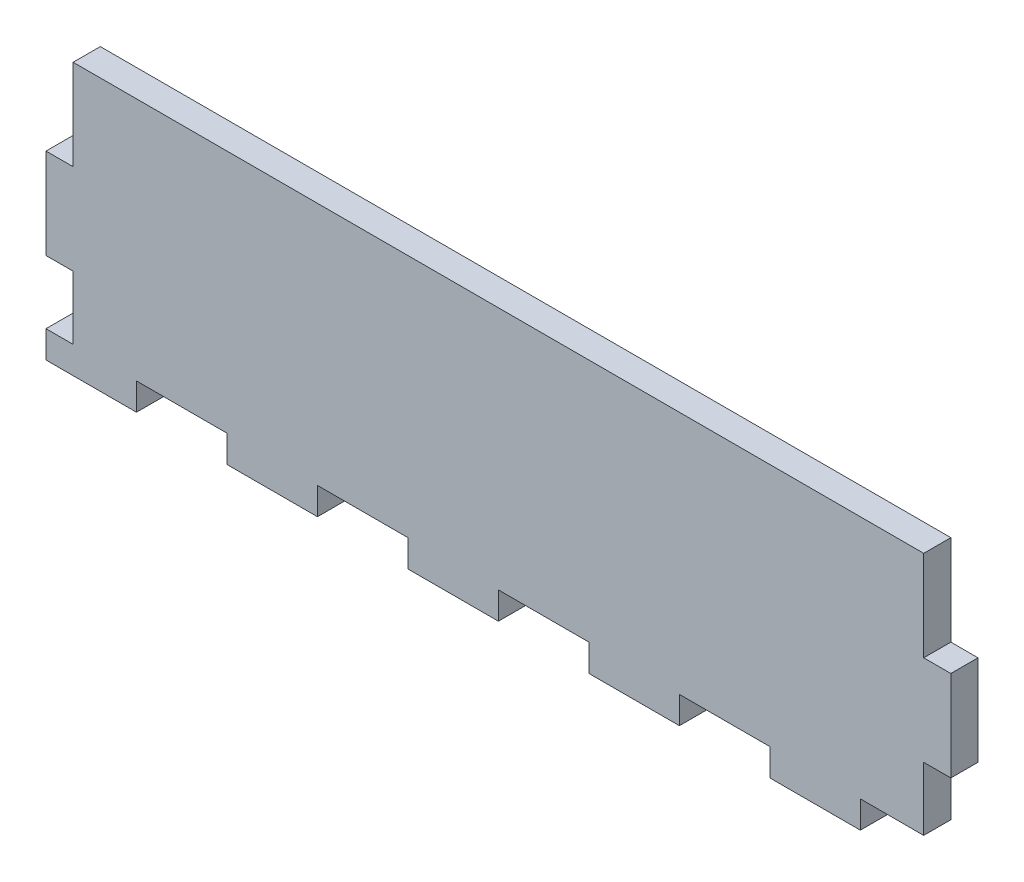
from build123d import *

# Parameters (mm, degrees)
SKETCH1_W           = 200
SKETCH1_H           = 60
BOSS_EXTRUDE1_DEPTH = 6
SKETCH2_W           = 20
SKETCH2_H           = 6
CUT_EXTRUDE1_DEPTH  = 10
LPATTERN1_COUNT     = 5
LPATTERN1_PITCH     = 40
SKETCH3_W           = 6
SKETCH3_H           = 20
CUT_EXTRUDE2_DEPTH  = 10
SKETCH4_W           = 6
SKETCH4_H           = 20
CUT_EXTRUDE3_DEPTH  = 10
SKETCH6_W           = 6
SKETCH6_H           = 14
CUT_EXTRUDE4_DEPTH  = 10
SKETCH7_W           = 6
SKETCH7_H           = 14
CUT_EXTRUDE5_DEPTH  = 10


with BuildPart() as part:
    # Sketch1 → Boss-Extrude1 (new body)
    with BuildSketch(Plane.XY):
        with Locations((-120.231213873, 116.098265896)):
            Rectangle(SKETCH1_W, SKETCH1_H)
    extrude(amount=BOSS_EXTRUDE1_DEPTH)

    # Sketch2 → Cut-Extrude1 (cut)
    with BuildSketch(Plane(origin=(0, 0, 0), x_dir=(-1, 0, 0), z_dir=(0, 0, -1))):
        with Locations((30.231213873, 89.098265896)):
            Rectangle(SKETCH2_W, SKETCH2_H)
    cut_extrude1 = extrude(amount=-CUT_EXTRUDE1_DEPTH, mode=Mode.SUBTRACT)

    # LPattern1: Cut-Extrude1 ×5
    with Locations(*[(-i * LPATTERN1_PITCH, 0, 0) for i in range(1, LPATTERN1_COUNT)]):
        add(cut_extrude1, mode=Mode.SUBTRACT)

    # Sketch3 → Cut-Extrude2 (cut)
    with BuildSketch(Plane(origin=(0, 0, 0), x_dir=(-1, 0, 0), z_dir=(0, 0, -1))):
        with Locations((217.231213873, 136.098265896)):
            Rectangle(SKETCH3_W, SKETCH3_H)
    extrude(amount=-CUT_EXTRUDE2_DEPTH, mode=Mode.SUBTRACT)

    # Sketch4 → Cut-Extrude3 (cut)
    with BuildSketch(Plane(origin=(0, 0, 0), x_dir=(-1, 0, 0), z_dir=(0, 0, -1))):
        with Locations((23.231213873, 136.098265896)):
            Rectangle(SKETCH4_W, SKETCH4_H)
    extrude(amount=-CUT_EXTRUDE3_DEPTH, mode=Mode.SUBTRACT)

    # Sketch6 → Cut-Extrude4 (cut)
    with BuildSketch(Plane(origin=(0, 0, 0), x_dir=(-1, 0, 0), z_dir=(0, 0, -1))):
        with Locations((217.231213873, 99.098265896)):
            Rectangle(SKETCH6_W, SKETCH6_H)
    extrude(amount=-CUT_EXTRUDE4_DEPTH, mode=Mode.SUBTRACT)

    # Sketch7 → Cut-Extrude5 (cut)
    with BuildSketch(Plane(origin=(0, 0, 0), x_dir=(-1, 0, 0), z_dir=(0, 0, -1))):
        with Locations((23.231213873, 99.098265896)):
            Rectangle(SKETCH7_W, SKETCH7_H)
    extrude(amount=-CUT_EXTRUDE5_DEPTH, mode=Mode.SUBTRACT)


solid = part.part
